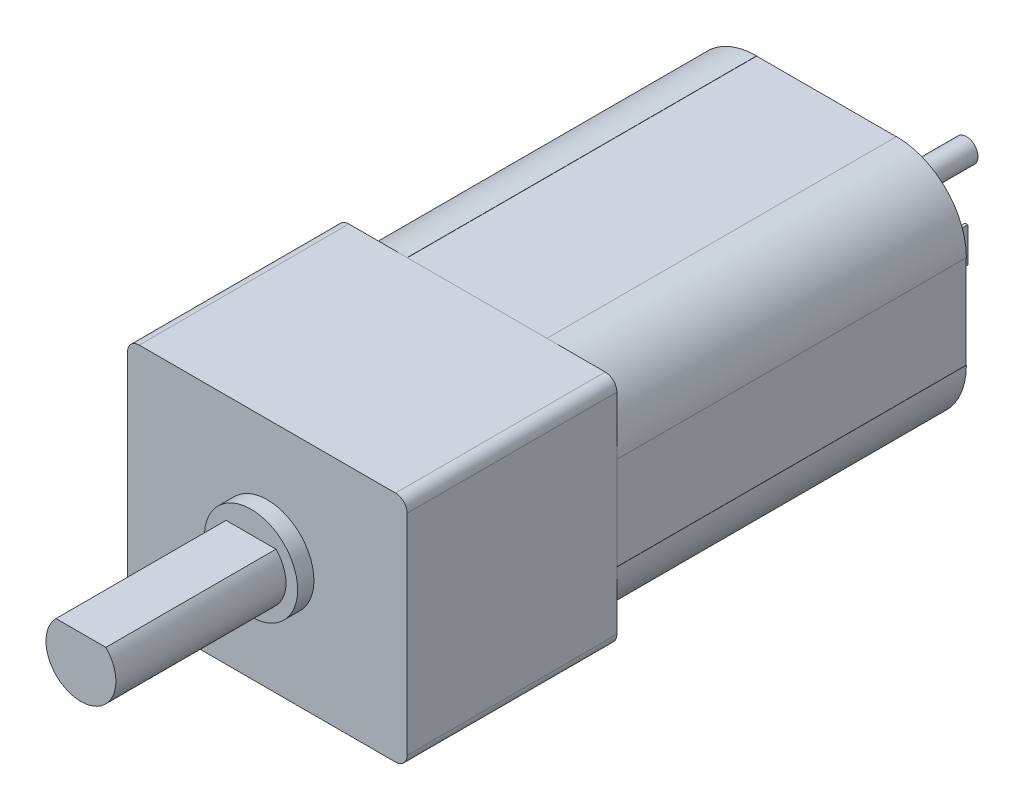
from build123d import *

# Parameters (mm, degrees)
TOP_W                                     = 12
TOP_H                                     = 10
PRECISION_MICRODRIVES_MODEL_212_109_DEPTH = 24
TOP_RING_2_R                              = 2
TOP_RING_DEPTH                            = 0.7
HOLE_WIZARD_M1_1_D                        = 1.1
HOLE_WIZARD_M1_1_DEPTH                    = 10
HOLE_WIZARD_M1_1_TIP                      = 0.337040433
HOLE_WIZARD_M1_2_D                        = 1.1
HOLE_WIZARD_M1_2_DEPTH                    = 10
HOLE_WIZARD_M1_2_TIP                      = 0.337040433
D_SHAFT_DEPTH                             = 8
VERRUNDUNG1_R                             = 3
SKIZZE12_R                                = 2.5
BOTTOM_DEPTH                              = 1.2
SKIZZE13_R                                = 0.5
BOLT_DEPTH                                = 6
SKIZZE14_W                                = 0.12
SKIZZE14_H                                = 1.5
FLAPS_DEPTH                               = 2.5
FLAP1_CUT_REACH                           = 33.881
SKIZZE15_R                                = 0.4
FLAP2_CUT_REACH                           = 33.881
SKIZZE16_R                                = 0.4
SKIZZE21_W                                = 12
SKIZZE21_H                                = 9
AUFSATZ_LINEAR_AUSTRAGEN2_DEPTH           = 10
SKIZZE22_W                                = 6
SKIZZE22_H                                = 15
SCHNITT_LINEAR_AUSTRAGEN3_DEPTH           = 0.01
SKIZZE23_W                                = 15
SKIZZE23_H                                = 4
SCHNITT_LINEAR_AUSTRAGEN4_DEPTH           = 0.01
SKIZZE24_W                                = 6
SKIZZE24_H                                = 15
SCHNITT_LINEAR_AUSTRAGEN5_DEPTH           = 0.01
SKIZZE25_W                                = 15
SKIZZE25_H                                = 4
SCHNITT_LINEAR_AUSTRAGEN6_DEPTH           = 0.01
VERRUNDUNG2_R                             = 0.5


with BuildPart() as part:
    # top → Precision Microdrives Model 212-109 (new body)
    with BuildSketch(Plane.XY):
        Rectangle(TOP_W, TOP_H)
    extrude(amount=-PRECISION_MICRODRIVES_MODEL_212_109_DEPTH)

    # top ring 2 → top-ring (add)
    with BuildSketch(Plane.XY):
        Circle(TOP_RING_2_R)
    extrude(amount=TOP_RING_DEPTH)

    # Hole Wizard M1-1
    with Locations(Plane.XY):
        with Locations((-4.5, 0)):
            Hole(HOLE_WIZARD_M1_1_D / 2, depth=HOLE_WIZARD_M1_1_DEPTH)
            with Locations((0, 0, -(HOLE_WIZARD_M1_1_DEPTH + HOLE_WIZARD_M1_1_TIP / 2))):  # 117° drill point
                Cone(0, HOLE_WIZARD_M1_1_D / 2, HOLE_WIZARD_M1_1_TIP, mode=Mode.SUBTRACT)

    # Hole Wizard M1-2
    with Locations(Plane.XY):
        with Locations((4.5, 0)):
            Hole(HOLE_WIZARD_M1_2_D / 2, depth=HOLE_WIZARD_M1_2_DEPTH)
            with Locations((0, 0, -(HOLE_WIZARD_M1_2_DEPTH + HOLE_WIZARD_M1_2_TIP / 2))):  # 117° drill point
                Cone(0, HOLE_WIZARD_M1_2_D / 2, HOLE_WIZARD_M1_2_TIP, mode=Mode.SUBTRACT)

    # Skizze11 → D-Shaft (add)
    with BuildSketch(Plane.XY):
        with BuildLine():
            Line((-1.071214264, 1.05), (1.071214264, 1.05))
            ThreePointArc((1.071214264, 1.05), (0, -1.5), (-1.071214264, 1.05))
        make_face()
    extrude(amount=D_SHAFT_DEPTH)

    # Verrundung1
    verrundung1_edges = [part.edges().sort_by_distance(p)[0] for p in [
        (-6, 5, -12),
        (6, 5, -12),
        (6, -5, -12),
        (-6, -5, -12),
    ]]
    fillet(verrundung1_edges, radius=VERRUNDUNG1_R)

    # Skizze12 → bottom (add)
    with BuildSketch(Plane(origin=(0, 0, -24), x_dir=(-1, 0, 0), z_dir=(0, 0, -1))):
        Circle(SKIZZE12_R)
    extrude(amount=BOTTOM_DEPTH)

    # Skizze13 → bolt (add)
    with BuildSketch(Plane(origin=(0, 0, -24), x_dir=(-1, 0, 0), z_dir=(0, 0, -1))):
        Circle(SKIZZE13_R)
    extrude(amount=BOLT_DEPTH)

    # Skizze14 → flaps (add)
    with BuildSketch(Plane(origin=(0, 0, -24), x_dir=(-1, 0, 0), z_dir=(0, 0, -1))):
        with Locations((-3.5, 0)):
            Rectangle(SKIZZE14_W, SKIZZE14_H)
        with Locations((3.5, 0)):
            Rectangle(SKIZZE14_W, SKIZZE14_H)
    extrude(amount=FLAPS_DEPTH)

    # Skizze15 → flap1-cut (cut, up to next)
    with BuildSketch(Plane.ZY.offset(3.56), mode=Mode.PRIVATE) as flap1_cut_sk1:
        with Locations((-25.7, 0)):
            Circle(SKIZZE15_R)
    flap1_cut_tool1 = extrude(flap1_cut_sk1.sketch, amount=-FLAP1_CUT_REACH, mode=Mode.PRIVATE) & part.part
    add(flap1_cut_tool1.solids().sort_by_distance((-3.56, 0, -25.7))[0], mode=Mode.SUBTRACT)

    # Skizze16 → flap2-cut (cut, up to next)
    with BuildSketch(Plane(origin=(3.56, 0, 0), x_dir=(0, 0, -1), z_dir=(1, 0, 0)), mode=Mode.PRIVATE) as flap2_cut_sk1:
        with Locations((25.7, 0)):
            Circle(SKIZZE16_R)
    flap2_cut_tool1 = extrude(flap2_cut_sk1.sketch, amount=-FLAP2_CUT_REACH, mode=Mode.PRIVATE) & part.part
    add(flap2_cut_tool1.solids().sort_by_distance((3.56, 0, -25.7))[0], mode=Mode.SUBTRACT)

    # Skizze21 → Aufsatz-Linear austragen2 (add)
    with BuildSketch(Plane(origin=(0, 5, 0), x_dir=(1, 0, 0), z_dir=(0, 1, 0))):
        with Locations((0, 4.5)):
            Rectangle(SKIZZE21_W, SKIZZE21_H)
    extrude(amount=-AUFSATZ_LINEAR_AUSTRAGEN2_DEPTH)

    # Skizze22 → Schnitt-Linear austragen3 (cut)
    with BuildSketch(Plane.XZ.offset(5)):
        with Locations((0, -16.5)):
            Rectangle(SKIZZE22_W, SKIZZE22_H)
    extrude(amount=-SCHNITT_LINEAR_AUSTRAGEN3_DEPTH, mode=Mode.SUBTRACT)

    # Skizze23 → Schnitt-Linear austragen4 (cut)
    with BuildSketch(Plane(origin=(6, 0, 0), x_dir=(0, 0, -1), z_dir=(1, 0, 0))):
        with Locations((16.5, 0)):
            Rectangle(SKIZZE23_W, SKIZZE23_H)
    extrude(amount=-SCHNITT_LINEAR_AUSTRAGEN4_DEPTH, mode=Mode.SUBTRACT)

    # Skizze24 → Schnitt-Linear austragen5 (cut)
    with BuildSketch(Plane(origin=(0, 5, 0), x_dir=(1, 0, 0), z_dir=(0, 1, 0))):
        with Locations((0, 16.5)):
            Rectangle(SKIZZE24_W, SKIZZE24_H)
    extrude(amount=-SCHNITT_LINEAR_AUSTRAGEN5_DEPTH, mode=Mode.SUBTRACT)

    # Skizze25 → Schnitt-Linear austragen6 (cut)
    with BuildSketch(Plane.ZY.offset(6)):
        with Locations((-16.5, 0)):
            Rectangle(SKIZZE25_W, SKIZZE25_H)
    extrude(amount=-SCHNITT_LINEAR_AUSTRAGEN6_DEPTH, mode=Mode.SUBTRACT)

    # Verrundung2
    verrundung2_edges = [part.edges().sort_by_distance(p)[0] for p in [
        (-6, -5, -4.5),
        (6, -5, -4.5),
        (6, 5, -4.5),
        (-6, 5, -4.5),
    ]]
    fillet(verrundung2_edges, radius=VERRUNDUNG2_R)


solid = part.part
